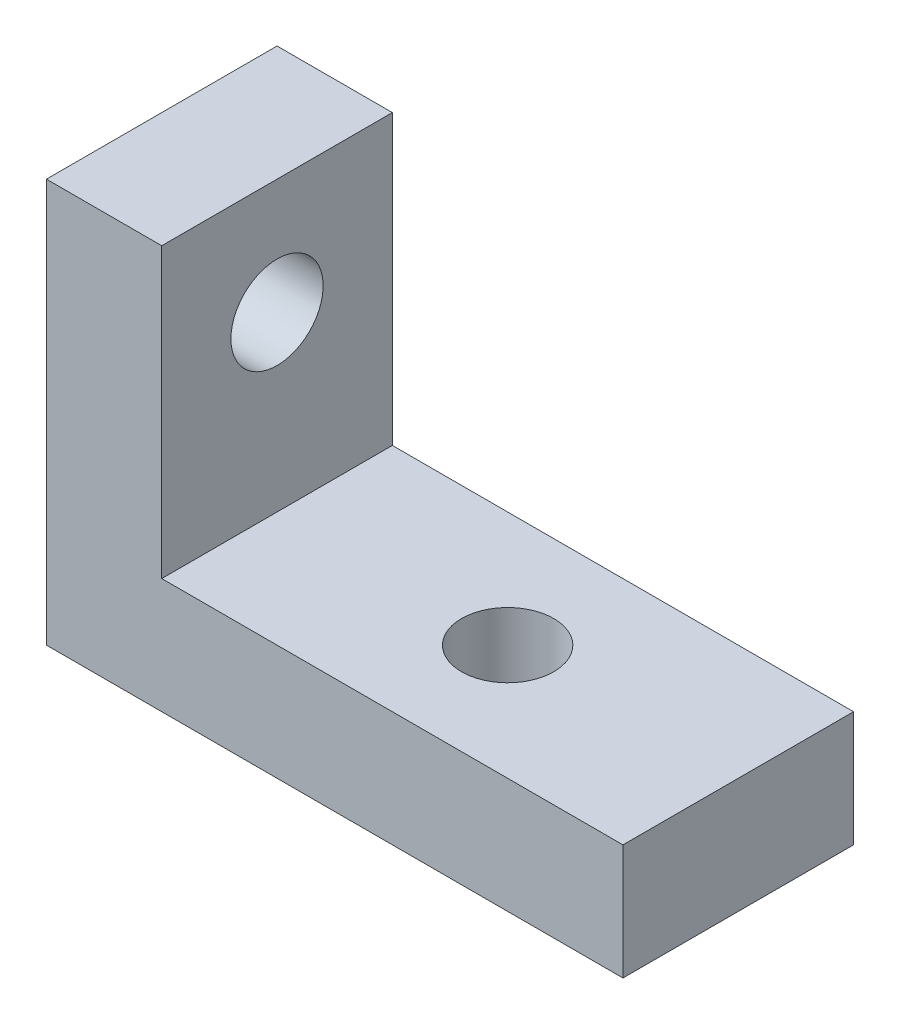
from build123d import *

# Parameters (mm, degrees)
BOSS_EXTRUDE2_DEPTH = 5.08
SKETCH3_R           = 1.016
CUT_EXTRUDE1_DEPTH  = 25.4
SKETCH4_R           = 1.016
CUT_EXTRUDE2_DEPTH  = 2.54


with BuildPart() as part:
    # Sketch1 → Boss-Extrude2 (new body)
    with BuildSketch(Plane.XY):
        Polygon((-15.917333333, -20.997333333), (-15.917333333, -29.887333333), (-3.217333333, -29.887333333), (-3.217333333, -27.347333333), (-13.377333333, -27.347333333), (-13.377333333, -20.997333333), align=None)
    extrude(amount=BOSS_EXTRUDE2_DEPTH)

    # Sketch3 → Cut-Extrude1 (cut)
    with BuildSketch(Plane(origin=(0, -27.347333333, 0), x_dir=(1, 0, 0), z_dir=(0, 1, 0))):
        with Locations((-8.297333333, -2.54)):
            Circle(SKETCH3_R)
    extrude(amount=-CUT_EXTRUDE1_DEPTH, mode=Mode.SUBTRACT)

    # Sketch4 → Cut-Extrude2 (cut)
    with BuildSketch(Plane.ZY.offset(15.917333333)):
        with Locations((2.54, -23.537333333)):
            Circle(SKETCH4_R)
    extrude(amount=-CUT_EXTRUDE2_DEPTH, mode=Mode.SUBTRACT)


solid = part.part
